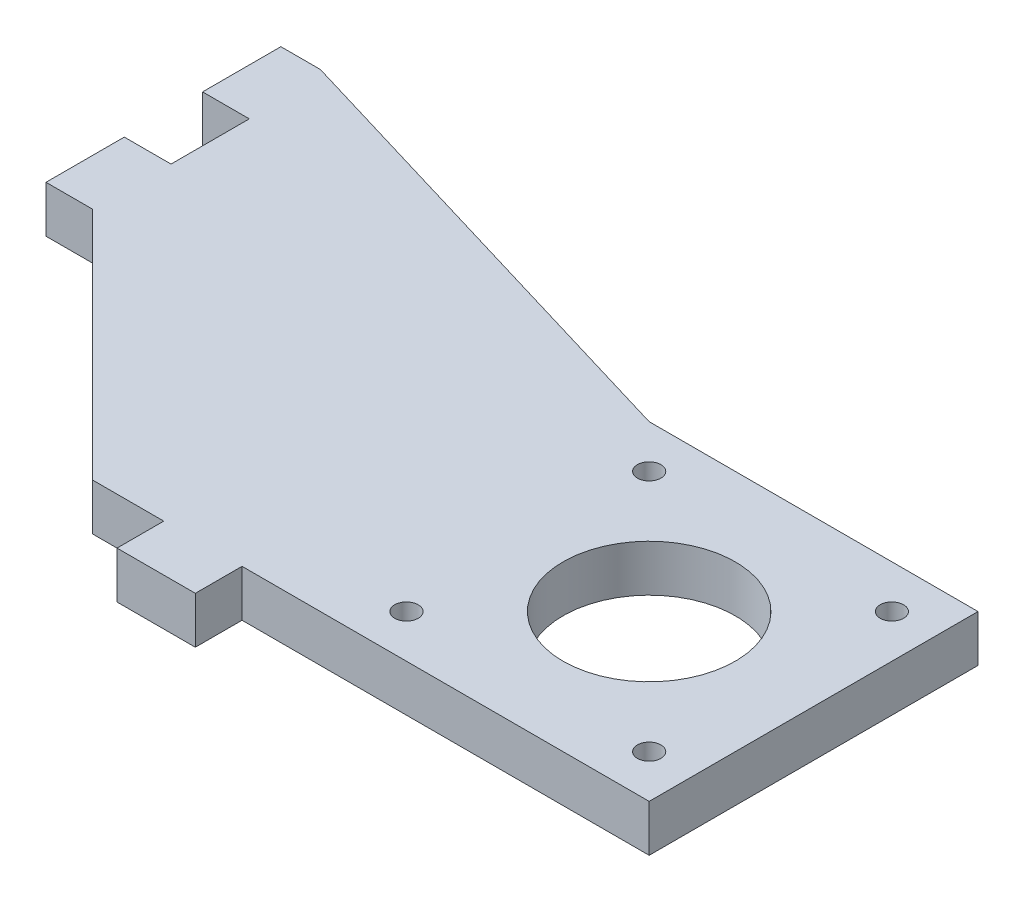
from build123d import *

# Parameters (mm, degrees)
BOSS_EXTRUDE1_DEPTH = 5.969
SKETCH2_R           = 11
SKETCH2_R_2         = 1.5
BOSS_EXTRUDE2_DEPTH = 5.969


with BuildPart() as part:
    # Sketch1 → Boss-Extrude1 (new body)
    with BuildSketch(Plane(origin=(0, 0, 0), x_dir=(1, 0, 0), z_dir=(0, 1, 0))):
        Polygon((0, 0), (-5.969, 0), (-5.969, 10), (0, 10), (0, 20), (-5.969, 20), (-5.969, 30), (-0.92804, 30), (59.031, -29.95904), (49.031, -29.95904), (49.031, -35.92804), (39.031, -35.92804), (39.031, -29.95904), (29.95904, -29.95904), align=None)
    extrude(amount=BOSS_EXTRUDE1_DEPTH)

    # Sketch2 → Boss-Extrude2 (add)
    with BuildSketch(Plane(origin=(0, 5.969, 0), x_dir=(1, 0, 0), z_dir=(0, 1, 0))):
        Polygon((59.031, -29.95904), (101.031, -29.95904), (101.031, 12.04096), (59.031, 12.04096), (-0.92804, 30), align=None)
        with Locations((80.031, -8.95904)):
            Circle(SKETCH2_R, mode=Mode.SUBTRACT)
        with Locations((64.531, 6.54096)):
            Circle(SKETCH2_R_2, mode=Mode.SUBTRACT)
        with Locations((95.531, 6.54096)):
            Circle(SKETCH2_R_2, mode=Mode.SUBTRACT)
        with Locations((64.531, -24.45904)):
            Circle(SKETCH2_R_2, mode=Mode.SUBTRACT)
        with Locations((95.531, -24.45904)):
            Circle(SKETCH2_R_2, mode=Mode.SUBTRACT)
    extrude(amount=-BOSS_EXTRUDE2_DEPTH)


solid = part.part
